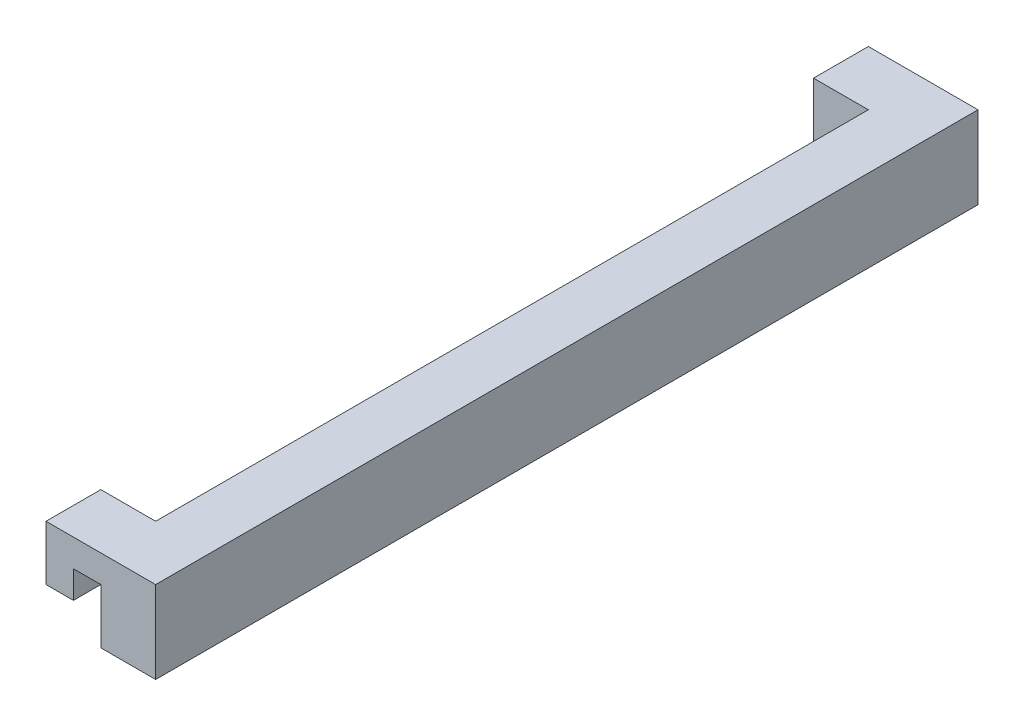
from build123d import *

# Parameters (mm, degrees)
BOSS_EXTRUDE1_DEPTH     = 30
CUT_EXTRUDE1_DEPTH      = 1
CUT_EXTRUDE1_DEPTH_BACK = 301


with BuildPart() as part:
    # Sketch3 → Boss-Extrude1 (new body)
    with BuildSketch(Plane(origin=(0, 0, 0), x_dir=(1, 0, 0), z_dir=(0, 1, 0))):
        Polygon((0, 0), (0, 20), (40, 20), (40, -280), (0, -280), (0, -260), (20, -260), (20, 0), align=None)
    extrude(amount=BOSS_EXTRUDE1_DEPTH)

    # Sketch4 → Cut-Extrude1 (cut, two sides)
    with BuildSketch(Plane.XY.offset(280)) as cut_extrude1_sk:
        Polygon((0, 10), (10, 10), (10, 20), (20, 20), (20, 0), (0, 0), align=None)
    extrude(amount=CUT_EXTRUDE1_DEPTH, mode=Mode.SUBTRACT)
    extrude(cut_extrude1_sk.sketch, amount=-CUT_EXTRUDE1_DEPTH_BACK, mode=Mode.SUBTRACT)


solid = part.part
